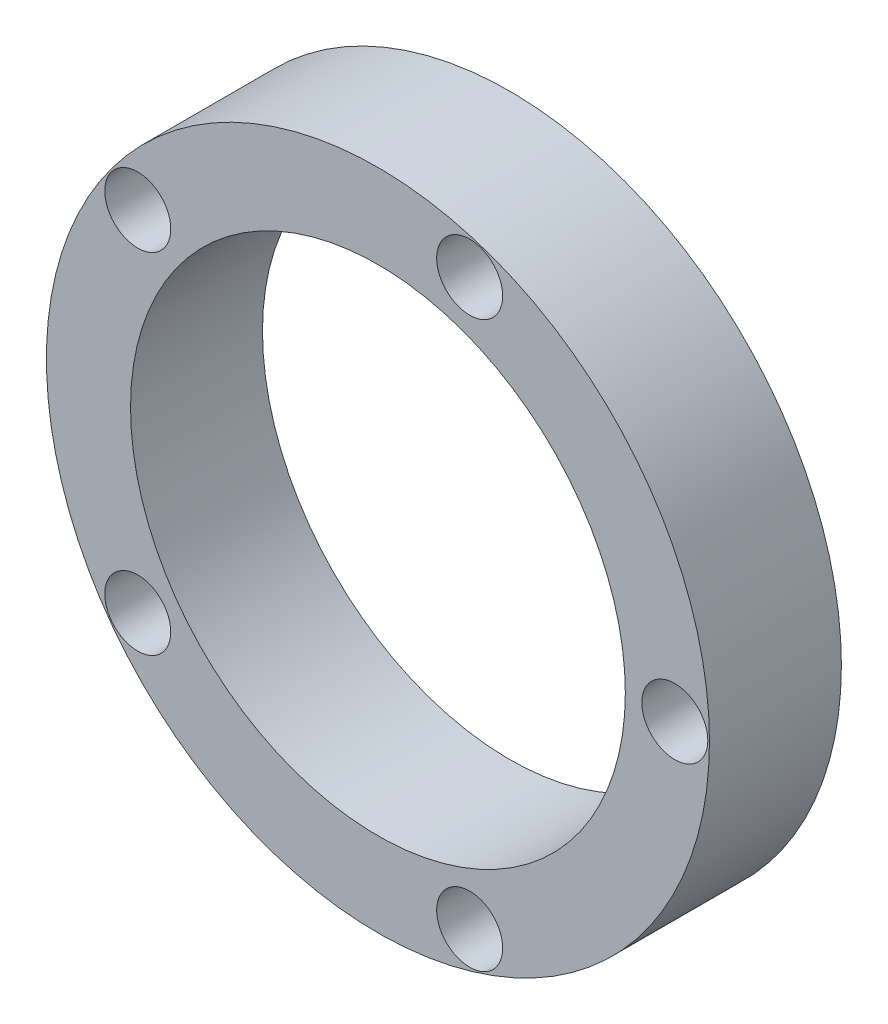
from build123d import *

# Parameters (mm, degrees)
SKETCH_1_R          = 12
SKETCH_1_R_2        = 1
EXTRUDE_1_DEPTH     = 2
SKETCH_3_R          = 1
EXTRUDE_2_DEPTH     = 12
SKETCH_4_R          = 7
CUT_EXTRUDE_1_DEPTH = 12
SKETCH_6_R          = 12
SKETCH_6_R_2        = 11.5
CUT_EXTRUDE_2_DEPTH = 4
SKETCH_8_R          = 11.5
SKETCH_8_R_2        = 7
EXTRUDE_4_DEPTH     = 2
SKETCH_9_R          = 7.5
CUT_EXTRUDE_3_DEPTH = 4
SKETCH_12_R         = 1
CUT_EXTRUDE_4_DEPTH = 20
SKETCH_13_R         = 11.5
SKETCH_13_R_2       = 10.05
CUT_EXTRUDE_5_DEPTH = 10


with BuildPart() as part:
    # 草图1 → 凸台-拉伸1 (new body)
    with BuildSketch(Plane.XY):
        Circle(SKETCH_1_R)
        with Locations((9, 0)):
            Circle(SKETCH_1_R_2, mode=Mode.SUBTRACT)
        with Locations((2.781152949, -8.559508647)):
            Circle(SKETCH_1_R_2, mode=Mode.SUBTRACT)
        with Locations((-7.281152949, -5.290067271)):
            Circle(SKETCH_1_R_2, mode=Mode.SUBTRACT)
        with Locations((-7.281152949, 5.290067271)):
            Circle(SKETCH_1_R_2, mode=Mode.SUBTRACT)
        with Locations((2.781152949, 8.559508647)):
            Circle(SKETCH_1_R_2, mode=Mode.SUBTRACT)
    extrude(amount=EXTRUDE_1_DEPTH)

    # 草图3 → 凸台-拉伸2 (add)
    with BuildSketch(Plane.XY.offset(2)):
        with Locations((9, 0)):
            Circle(SKETCH_3_R)
        with Locations((2.781152949, -8.559508647)):
            Circle(SKETCH_3_R)
        with Locations((-7.281152949, -5.290067271)):
            Circle(SKETCH_3_R)
        with Locations((-7.281152949, 5.290067271)):
            Circle(SKETCH_3_R)
        with Locations((2.781152949, 8.559508647)):
            Circle(SKETCH_3_R)
    extrude(amount=-EXTRUDE_2_DEPTH)

    # 草图4 → 切除-拉伸1 (cut)
    with BuildSketch(Plane(origin=(0, 0, 0), x_dir=(-1, 0, 0), z_dir=(0, 0, -1))):
        Circle(SKETCH_4_R)
    extrude(amount=-CUT_EXTRUDE_1_DEPTH, mode=Mode.SUBTRACT)

    # 草图6 → 切除-拉伸2 (cut)
    with BuildSketch(Plane(origin=(0, 0, 0), x_dir=(-1, 0, 0), z_dir=(0, 0, -1))):
        Circle(SKETCH_6_R)
        Circle(SKETCH_6_R_2, mode=Mode.SUBTRACT)
    extrude(amount=-CUT_EXTRUDE_2_DEPTH, mode=Mode.SUBTRACT)

    # 草图8 → 凸台-拉伸4 (add)
    with BuildSketch(Plane.XY.offset(2)):
        Circle(SKETCH_8_R)
        Circle(SKETCH_8_R_2, mode=Mode.SUBTRACT)
    extrude(amount=EXTRUDE_4_DEPTH)

    # 草图9 → 切除-拉伸3 (cut)
    with BuildSketch(Plane(origin=(0, 0, 0), x_dir=(-1, 0, 0), z_dir=(0, 0, -1))):
        Circle(SKETCH_9_R)
    extrude(amount=-CUT_EXTRUDE_3_DEPTH, mode=Mode.SUBTRACT)

    # 草图12 → 切除-拉伸4 (cut)
    with BuildSketch(Plane(origin=(0, 0, -10), x_dir=(-1, 0, 0), z_dir=(0, 0, -1))):
        with Locations((-2.781152949, -8.559508647)):
            Circle(SKETCH_12_R)
        with Locations((7.281152949, 5.290067271)):
            Circle(SKETCH_12_R)
        with Locations((-2.781152949, 8.559508647)):
            Circle(SKETCH_12_R)
        with Locations((-9, 0)):
            Circle(SKETCH_12_R)
        with Locations((7.281152949, -5.290067271)):
            Circle(SKETCH_12_R)
    extrude(amount=-CUT_EXTRUDE_4_DEPTH, mode=Mode.SUBTRACT)

    # 草图13 → 切除-拉伸5 (cut)
    with BuildSketch(Plane.XY.offset(4)):
        Circle(SKETCH_13_R)
        Circle(SKETCH_13_R_2, mode=Mode.SUBTRACT)
    extrude(amount=-CUT_EXTRUDE_5_DEPTH, mode=Mode.SUBTRACT)


solid = part.part
